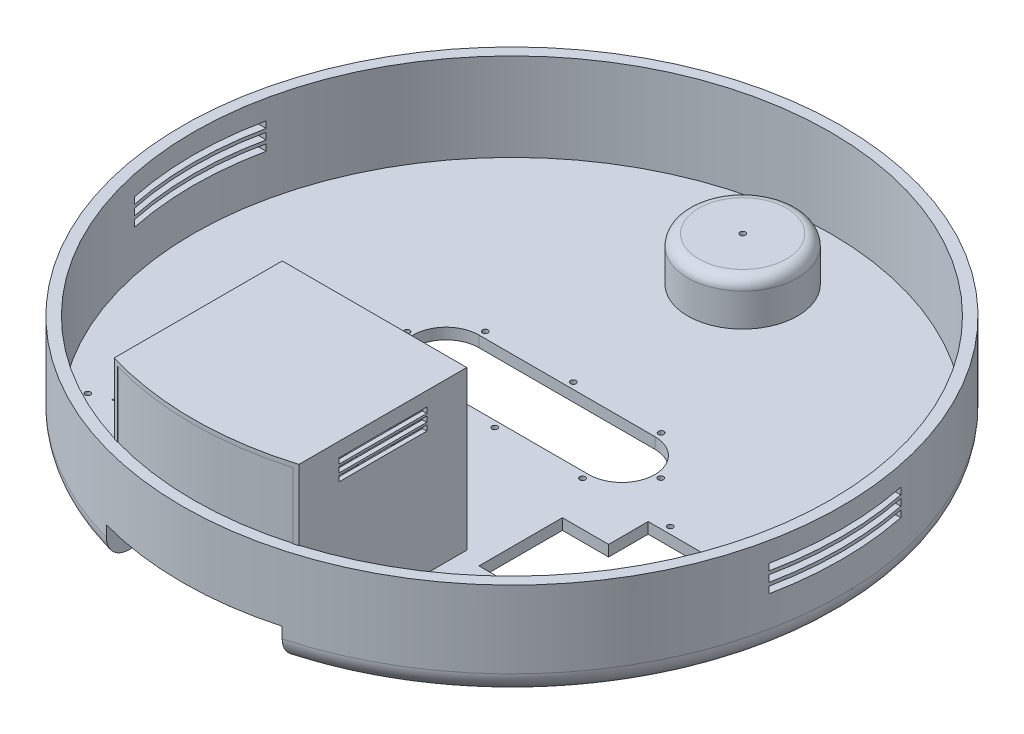
from build123d import *

# Parameters (mm, degrees)
SKETCH1_R                = 150
BOSS_EXTRUDE1_DEPTH      = 45
SHELL1_T                 = -5
SKETCH2_W                = 26
SKETCH2_H                = 74
CUT_EXTRUDE1_DEPTH       = 216.870331449
CUT_EXTRUDE1_DEPTH_BACK  = 216.870331449
SKETCH3_R                = 1.25
CUT_EXTRUDE2_DEPTH       = 216.870331449
CUT_EXTRUDE2_DEPTH_BACK  = 216.870331449
FILLET5_R                = 10
SKETCH13_W               = 21.020003018
SKETCH13_H               = 38
CUT_EXTRUDE5_DEPTH       = 217.85248456
SKETCH14_R               = 20
CUT_EXTRUDE6_DEPTH       = 216.870331588
CUT_EXTRUDE6_DEPTH_BACK  = 216.870331588
SKETCH15_R               = 25
BOSS_EXTRUDE3_DEPTH      = 20
SKETCH16_R               = 20
CUT_EXTRUDE7_DEPTH       = 15
CUT_EXTRUDE8_DEPTH       = 10
CUT_EXTRUDE8_DEPTH_BACK  = 216.870331588
FILLET7_R                = 5
BOSS_EXTRUDE4_DEPTH      = 70
BOSS_EXTRUDE7_DEPTH      = 60
BOSS_EXTRUDE8_DEPTH      = 2
SKETCH29_R               = 1.25
CUT_EXTRUDE9_DEPTH       = 219.412453995
CUT_EXTRUDE9_DEPTH_BACK  = 219.412453995
SKETCH30_R               = 15
SKETCH30_R_2             = 1.25
CUT_EXTRUDE10_DEPTH      = 2
SKETCH31_W               = 40
SKETCH31_H               = 2.5
SKETCH31_H_2             = 2.49925277
CUT_EXTRUDE11_DEPTH      = 256.524949992
CUT_EXTRUDE11_DEPTH_BACK = 256.524949992
SKETCH32_W               = 60
SKETCH32_H               = 3
CUT_EXTRUDE12_DEPTH      = 226.674544555
CUT_EXTRUDE12_DEPTH_BACK = 226.674544555


with BuildPart() as part:
    # Sketch1 → Boss-Extrude1 (new body)
    with BuildSketch(Plane(origin=(0, 0, 0), x_dir=(1, 0, 0), z_dir=(0, 1, 0))):
        with Locations(Location((0, 0, 0), (0, 0, 90))):
            Circle(SKETCH1_R)
    extrude(amount=BOSS_EXTRUDE1_DEPTH)

    # Shell1
    shell1_openings = [part.faces().sort_by_distance(p)[0] for p in [
        (0, 45, 0),
    ]]
    offset(amount=SHELL1_T, openings=shell1_openings, kind=Kind.INTERSECTION)

    # Sketch2 → Cut-Extrude1 (cut, two sides)
    with BuildSketch(Plane(origin=(0, 5, 0), x_dir=(1, 0, 0), z_dir=(0, 1, 0))) as cut_extrude1_sk:
        with Locations((85, -47)):
            Rectangle(SKETCH2_W, SKETCH2_H)
        with Locations((-85, -47)):
            Rectangle(SKETCH2_W, SKETCH2_H)
    extrude(amount=CUT_EXTRUDE1_DEPTH, mode=Mode.SUBTRACT)
    extrude(cut_extrude1_sk.sketch, amount=-CUT_EXTRUDE1_DEPTH_BACK, mode=Mode.SUBTRACT)

    # Sketch3 → Cut-Extrude2 (cut, two sides)
    with BuildSketch(Plane(origin=(0, 5, 0), x_dir=(1, 0, 0), z_dir=(0, 1, 0))) as cut_extrude2_sk:
        with Locations(Location((0, 27.883333333, 0), (0, 0, 270))):
            Circle(SKETCH3_R)
        with Locations(Location((-57.75, 10, 0), (0, 0, 270))):
            Circle(SKETCH3_R)
        with Locations(Location((-40, 27.883333333, 0), (0, 0, 270))):
            Circle(SKETCH3_R)
        with Locations(Location((40, 27.883333333, 0), (0, 0, 270))):
            Circle(SKETCH3_R)
        with Locations(Location((40, -7.883333333, 0), (0, 0, 270))):
            Circle(SKETCH3_R)
        with Locations(Location((0, -7.883333333, 0), (0, 0, 270))):
            Circle(SKETCH3_R)
        with Locations(Location((-40, -7.883333333, 0), (0, 0, 270))):
            Circle(SKETCH3_R)
        with Locations(Location((57.75, 10, 0), (0, 0, 270))):
            Circle(SKETCH3_R)
        with Locations(Location((-106, -6.92655, 0), (0, 0, 270))):
            Circle(SKETCH3_R)
        with Locations(Location((-79, -6.92655, 0), (0, 0, 270))):
            Circle(SKETCH3_R)
        with Locations(Location((-79, -87.07345, 0), (0, 0, 270))):
            Circle(SKETCH3_R)
        with Locations(Location((-106, -87.07345, 0), (0, 0, 270))):
            Circle(SKETCH3_R)
        with Locations(Location((106, -87.07345, 0), (0, 0, 270))):
            Circle(SKETCH3_R)
        with Locations(Location((79, -87.07345, 0), (0, 0, 270))):
            Circle(SKETCH3_R)
        with Locations(Location((79, -6.92655, 0), (0, 0, 270))):
            Circle(SKETCH3_R)
        with Locations(Location((106, -6.92655, 0), (0, 0, 270))):
            Circle(SKETCH3_R)
        with BuildLine():
            Line((-40, 25), (40, 25))
            ThreePointArc((40, 25), (55, 10), (40, -5))
            Line((40, -5), (-40, -5))
            ThreePointArc((-40, -5), (-55, 10), (-40, 25))
        make_face()
    extrude(amount=CUT_EXTRUDE2_DEPTH, mode=Mode.SUBTRACT)
    extrude(cut_extrude2_sk.sketch, amount=-CUT_EXTRUDE2_DEPTH_BACK, mode=Mode.SUBTRACT)

    # Fillet5
    fillet5_edges = [part.edges().sort_by_distance(p)[0] for p in [
        (0, 0, 150),
    ]]
    fillet(fillet5_edges, radius=FILLET5_R)

    # Sketch13 → Cut-Extrude5 (cut, symmetric)
    with BuildSketch(Plane.XZ):
        with Locations((61.489998491, 47)):
            Rectangle(SKETCH13_W, SKETCH13_H)
    cut_extrude5 = extrude(amount=CUT_EXTRUDE5_DEPTH, both=True, mode=Mode.SUBTRACT)

    # Mirror2: Cut-Extrude5 across plane
    add(cut_extrude5.mirror(Plane(origin=(0, 0, 0), x_dir=(0, 0, 1), z_dir=(1, 0, 0))), mode=Mode.SUBTRACT)

    # Sketch14 → Cut-Extrude6 (cut, two sides)
    with BuildSketch(Plane(origin=(0, 5, 0), x_dir=(1, 0, 0), z_dir=(0, 1, 0))) as cut_extrude6_sk:
        with Locations(Location((0, 105, 0), (0, 0, 270))):
            Circle(SKETCH14_R)
    extrude(amount=CUT_EXTRUDE6_DEPTH, mode=Mode.SUBTRACT)
    extrude(cut_extrude6_sk.sketch, amount=-CUT_EXTRUDE6_DEPTH_BACK, mode=Mode.SUBTRACT)

    # Sketch15 → Boss-Extrude3 (add)
    with BuildSketch(Plane(origin=(0, 5, 0), x_dir=(1, 0, 0), z_dir=(0, 1, 0))):
        with Locations(Location((0, 105, 0), (0, 0, 270))):
            Circle(SKETCH15_R)
    extrude(amount=BOSS_EXTRUDE3_DEPTH)

    # Sketch16 → Cut-Extrude7 (cut)
    with BuildSketch(Plane.XZ.offset(-5)):
        with Locations(Location((0, -105, 0), (0, 0, 90))):
            Circle(SKETCH16_R)
    extrude(amount=-CUT_EXTRUDE7_DEPTH, mode=Mode.SUBTRACT)

    # Sketch21 → Cut-Extrude8 (cut, two sides)
    with BuildSketch(Plane(origin=(0, 5, 0), x_dir=(1, 0, 0), z_dir=(0, 1, 0))) as cut_extrude8_sk:
        with BuildLine():
            Line((-40, -144.568322948), (-40, -64.568322948))
            Line((-40, -64.568322948), (40, -64.568322948))
            Line((40, -64.568322948), (40, -144.568322948))
            ThreePointArc((40, -144.568322948), (0, -150), (-40, -144.568322948))
        make_face()
    extrude(amount=CUT_EXTRUDE8_DEPTH, mode=Mode.SUBTRACT)
    extrude(cut_extrude8_sk.sketch, amount=-CUT_EXTRUDE8_DEPTH_BACK, mode=Mode.SUBTRACT)

    # Fillet7
    fillet7_edges = [part.edges().sort_by_distance(p)[0] for p in [
        (0, 25, -130),
        (0, 20, -125),
    ]]
    fillet(fillet7_edges, radius=FILLET7_R)

    # Sketch23 → Boss-Extrude4 (add)
    with BuildSketch(Plane(origin=(0, 5, 0), x_dir=(1, 0, 0), z_dir=(0, 1, 0))):
        with BuildLine():
            Line((-40, -64.568322948), (-40, -139.568322948))
            ThreePointArc((-40, -139.568322948), (-41.001056838, -139.277529087), (-42, -138.979555225))
            Line((-42, -138.979555225), (-42, -62.568322948))
            Line((-42, -62.568322948), (42, -62.568322948))
            Line((42, -62.568322948), (42, -138.979555225))
            ThreePointArc((42, -138.979555225), (41.001056838, -139.277529087), (40, -139.568322948))
            Line((40, -139.568322948), (40, -64.568322948))
            Line((40, -64.568322948), (-40, -64.568322948))
        make_face()
    extrude(amount=BOSS_EXTRUDE4_DEPTH)

    # Sketch26 → Boss-Extrude7 (add)
    with BuildSketch(Plane(origin=(0, 75, 0), x_dir=(1, 0, 0), z_dir=(0, 1, 0))):
        with BuildLine():
            Line((-40, -137.291660344), (-40, -139.373598648))
            ThreePointArc((-40, -139.373598648), (0, -145), (40, -139.373598648))
            Line((40, -139.373598648), (40, -137.291660344))
            ThreePointArc((40, -137.291660344), (0, -143), (-40, -137.291660344))
        make_face()
    extrude(amount=-BOSS_EXTRUDE7_DEPTH)

    # Sketch27 → Boss-Extrude8 (add)
    with BuildSketch(Plane(origin=(0, 75, 0), x_dir=(1, 0, 0), z_dir=(0, 1, 0))):
        with BuildLine():
            Line((-42, -138.979555225), (-42, -62.568322948))
            Line((-42, -62.568322948), (42, -62.568322948))
            Line((42, -62.568322948), (42, -138.979555225))
            ThreePointArc((42, -138.979555225), (0, -145.187178396), (-42, -138.979555225))
        make_face()
    extrude(amount=BOSS_EXTRUDE8_DEPTH)

    # Sketch29 → Cut-Extrude9 (cut, two sides)
    with BuildSketch(Plane(origin=(0, 25, 0), x_dir=(1, 0, 0), z_dir=(0, 1, 0))) as cut_extrude9_sk:
        with Locations(Location((0, 105, 0), (0, 0, 270))):
            Circle(SKETCH29_R)
    extrude(amount=CUT_EXTRUDE9_DEPTH, mode=Mode.SUBTRACT)
    extrude(cut_extrude9_sk.sketch, amount=-CUT_EXTRUDE9_DEPTH_BACK, mode=Mode.SUBTRACT)

    # Sketch30 → Cut-Extrude10 (cut)
    with BuildSketch(Plane(origin=(0, 0, 62.568322948), x_dir=(-1, 0, 0), z_dir=(0, 0, -1))):
        with Locations((5, 31.25)):
            Circle(SKETCH30_R)
        with Locations((5, 48)):
            Circle(SKETCH30_R_2)
        with Locations((21.75, 31.25)):
            Circle(SKETCH30_R_2)
        with Locations((-11.75, 31.25)):
            Circle(SKETCH30_R_2)
        with Locations((5, 14.5)):
            Circle(SKETCH30_R_2)
    extrude(amount=-CUT_EXTRUDE10_DEPTH, mode=Mode.SUBTRACT)

    # Sketch31 → Cut-Extrude11 (cut, two sides)
    with BuildSketch(Plane(origin=(42, 0, 0), x_dir=(0, 0, -1), z_dir=(1, 0, 0))) as cut_extrude11_sk:
        with Locations((-100.773322948, 69.25)):
            Rectangle(SKETCH31_W, SKETCH31_H)
        with Locations((-100.773322948, 65.75)):
            Rectangle(SKETCH31_W, SKETCH31_H_2)
        with Locations((-100.773322948, 62.25)):
            Rectangle(SKETCH31_W, SKETCH31_H)
    extrude(amount=CUT_EXTRUDE11_DEPTH, mode=Mode.SUBTRACT)
    extrude(cut_extrude11_sk.sketch, amount=-CUT_EXTRUDE11_DEPTH_BACK, mode=Mode.SUBTRACT)

    # Sketch32 → Cut-Extrude12 (cut, two sides)
    with BuildSketch(Plane(origin=(0, 0, 0), x_dir=(0, 0, -1), z_dir=(1, 0, 0))) as cut_extrude12_sk:
        with Locations((0, 25.5)):
            Rectangle(SKETCH32_W, SKETCH32_H)
        with Locations((0, 30)):
            Rectangle(SKETCH32_W, SKETCH32_H)
        with Locations((0, 34.5)):
            Rectangle(SKETCH32_W, SKETCH32_H)
    extrude(amount=CUT_EXTRUDE12_DEPTH, mode=Mode.SUBTRACT)
    extrude(cut_extrude12_sk.sketch, amount=-CUT_EXTRUDE12_DEPTH_BACK, mode=Mode.SUBTRACT)


solid = part.part
